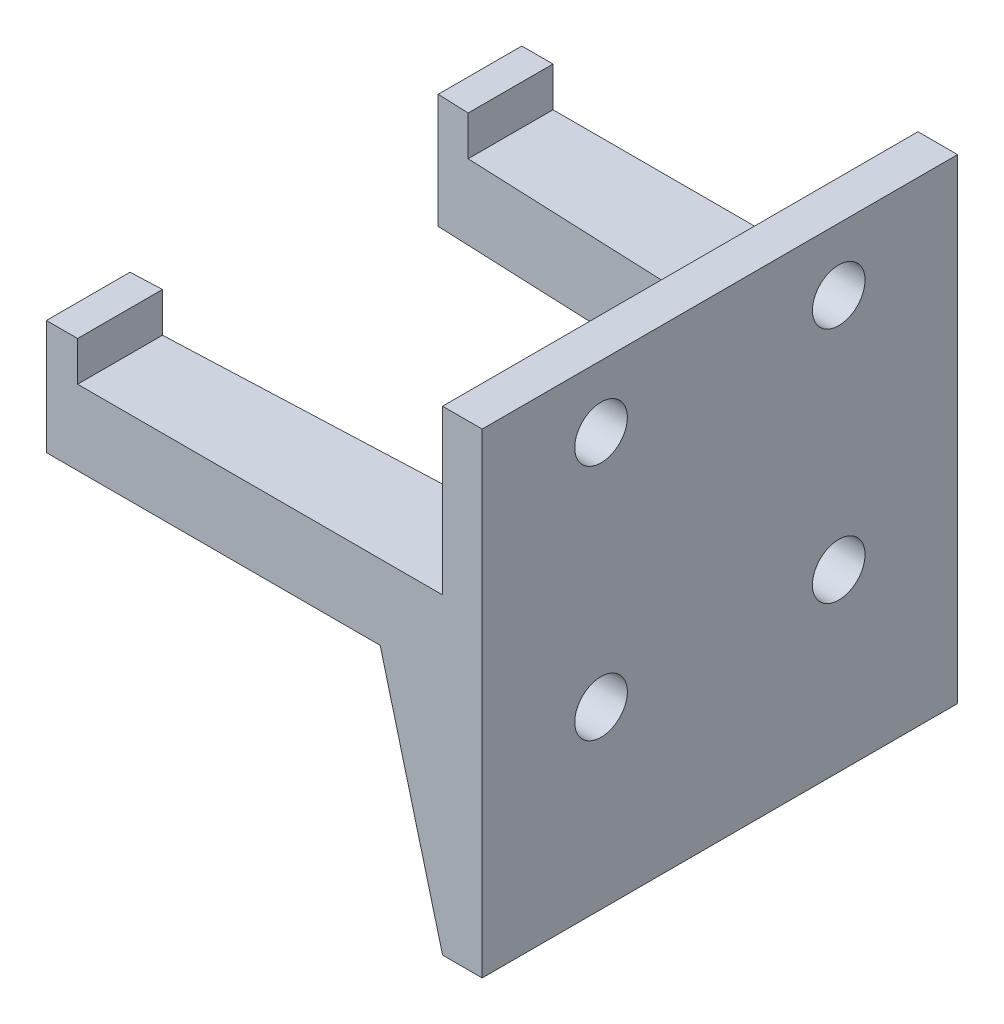
from build123d import *

# Parameters (mm, degrees)
BOSS_EXTRUDE1_DEPTH     = 76.2
SKETCH2_W               = 70
SKETCH2_H               = 43.942
CUT_EXTRUDE1_DEPTH      = 76.2
SKETCH3_R               = 4.2164
CUT_EXTRUDE2_DEPTH      = 6.35
CUT_EXTRUDE2_DEPTH_BACK = 58.5
SKETCH3_3_R             = 8.89
SKETCH3_3_R_2           = 4.2164
CUT_EXTRUDE3_DEPTH      = 10


with BuildPart() as part:
    # Sketch1 → Boss-Extrude1 (new body)
    with BuildSketch(Plane.XY):
        Polygon((6.35, 0), (0, 0), (0, -26.2), (-58.5, -26.2), (-58.5, -19.85), (-63.5, -19.85), (-63.5, -38.2), (-10, -38.2), (0, -76.2), (6.35, -76.2), align=None)
    extrude(amount=BOSS_EXTRUDE1_DEPTH)

    # Sketch2 → Cut-Extrude1 (cut)
    with BuildSketch(Plane(origin=(0, 0, 0), x_dir=(1, 0, 0), z_dir=(0, 1, 0))):
        Polygon((0, -16.129), (0, -16.029), (-70, -13.129), (-70, -16.129), align=None)
        with Locations((-35, -38.1)):
            Rectangle(SKETCH2_W, SKETCH2_H)
        Polygon((0, -60.171), (-70, -63.071), (-70, -60.071), (0, -60.071), align=None)
    extrude(amount=-CUT_EXTRUDE1_DEPTH, mode=Mode.SUBTRACT)

    # Sketch3 → Cut-Extrude2 (cut, two sides)
    with BuildSketch(Plane(origin=(0, 0, 0), x_dir=(0, 0, -1), z_dir=(1, 0, 0))) as cut_extrude2_sk:
        with Locations((-19.05, -10)):
            Circle(SKETCH3_R)
        with Locations((-57.15, -10)):
            Circle(SKETCH3_R)
        with Locations((-57.15, -48.1)):
            Circle(SKETCH3_R)
        with Locations((-19.05, -48.1)):
            Circle(SKETCH3_R)
    extrude(amount=CUT_EXTRUDE2_DEPTH, mode=Mode.SUBTRACT)
    extrude(cut_extrude2_sk.sketch, amount=-CUT_EXTRUDE2_DEPTH_BACK, mode=Mode.SUBTRACT)

    # Sketch3_3 → Cut-Extrude3 (cut)
    with BuildSketch(Plane(origin=(0, 0, 0), x_dir=(0, 0, -1), z_dir=(1, 0, 0))):
        with Locations((-19.05, -48.1)):
            Circle(SKETCH3_3_R)
        with Locations((-19.05, -48.1)):
            Circle(SKETCH3_3_R_2, mode=Mode.SUBTRACT)
        with Locations((-57.15, -48.1)):
            Circle(SKETCH3_3_R)
        with Locations((-57.15, -48.1)):
            Circle(SKETCH3_3_R_2, mode=Mode.SUBTRACT)
    extrude(amount=-CUT_EXTRUDE3_DEPTH, mode=Mode.SUBTRACT)


solid = part.part
